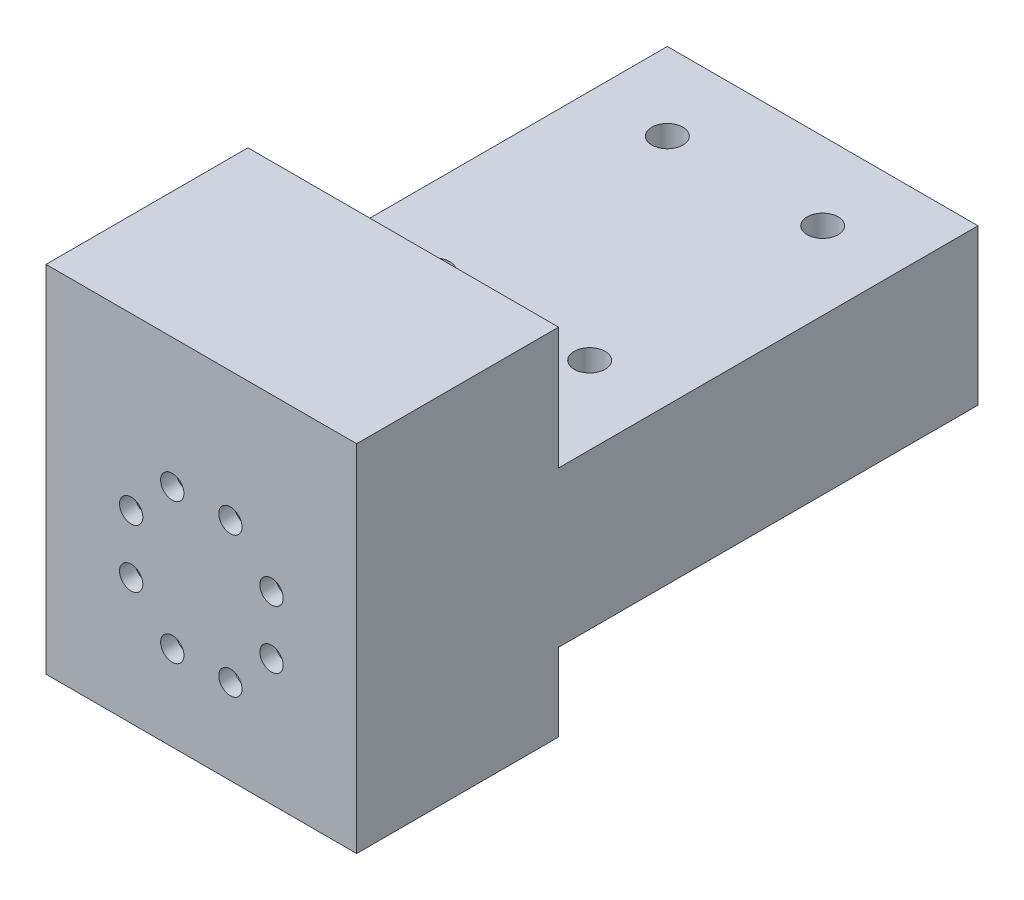
from build123d import *

# Parameters (mm, degrees)
CROQUIS1_W              = 40
CROQUIS1_H              = 40
SALIENTE_EXTRUIR1_DEPTH = 4
CROQUIS2_R              = 1.5
CORTAR_EXTRUIR1_DEPTH   = 4
SALIENTE_EXTRUIR2_DEPTH = 20
CROQUIS4_W              = 40
CROQUIS4_H              = 40
SALIENTE_EXTRUIR3_DEPTH = 4
CROQUIS6_W              = 40
CROQUIS6_H              = 40
CORTAR_EXTRUIR3_DEPTH   = 2
CROQUIS7_W              = 40
CROQUIS7_H              = 20
SALIENTE_EXTRUIR4_DEPTH = 80
CROQUIS8_R              = 2
CORTAR_EXTRUIR4_DEPTH   = 31
CROQUIS9_R              = 2
CORTAR_EXTRUIR5_DEPTH   = 31
CROQUIS11_W             = 40
CROQUIS11_H             = 20
CORTAR_EXTRUIR6_DEPTH   = 26
CROQUIS13_W             = 40
CROQUIS13_H             = 26
SALIENTE_EXTRUIR5_DEPTH = 5.7


with BuildPart() as part:
    # Croquis1 → Saliente-Extruir1 (new body)
    with BuildSketch(Plane.XY):
        Rectangle(CROQUIS1_W, CROQUIS1_H)
    extrude(amount=SALIENTE_EXTRUIR1_DEPTH)

    # Croquis2 → Cortar-Extruir1 (cut)
    with BuildSketch(Plane.XY.offset(4)):
        with Locations((-9.034617948, -3.742261285)):
            Circle(CROQUIS2_R)
        with Locations((-9.034617948, 3.742261285)):
            Circle(CROQUIS2_R)
        with Locations((-3.742261285, 9.034617948)):
            Circle(CROQUIS2_R)
        with Locations((3.742261285, 9.034617948)):
            Circle(CROQUIS2_R)
        with Locations((9.034617948, 3.742261285)):
            Circle(CROQUIS2_R)
        with Locations((9.034617948, -3.742261285)):
            Circle(CROQUIS2_R)
        with Locations((3.742261285, -9.034617948)):
            Circle(CROQUIS2_R)
        with Locations((-3.742261285, -9.034617948)):
            Circle(CROQUIS2_R)
    extrude(amount=-CORTAR_EXTRUIR1_DEPTH, mode=Mode.SUBTRACT)

    # Croquis3 → Saliente-Extruir2 (add)
    with BuildSketch(Plane(origin=(0, 0, 0), x_dir=(-1, 0, 0), z_dir=(0, 0, -1))):
        Polygon((-16, -20), (-16, -16), (-16, 16), (16, 16), (16, -16), (16, -20), (20, -20), (20, 20), (-20, 20), (-20, -20), align=None)
    extrude(amount=SALIENTE_EXTRUIR2_DEPTH)

    # Croquis4 → Saliente-Extruir3 (add)
    with BuildSketch(Plane(origin=(0, 0, -20), x_dir=(-1, 0, 0), z_dir=(0, 0, -1))):
        Rectangle(CROQUIS4_W, CROQUIS4_H)
    extrude(amount=SALIENTE_EXTRUIR3_DEPTH)

    # Croquis6 → Cortar-Extruir3 (cut)
    with BuildSketch(Plane.XY.offset(4)):
        Rectangle(CROQUIS6_W, CROQUIS6_H)
    extrude(amount=-CORTAR_EXTRUIR3_DEPTH, mode=Mode.SUBTRACT)

    # Croquis7 → Saliente-Extruir4 (add)
    with BuildSketch(Plane(origin=(0, 0, -24), x_dir=(-1, 0, 0), z_dir=(0, 0, -1))):
        Rectangle(CROQUIS7_W, CROQUIS7_H)
    extrude(amount=SALIENTE_EXTRUIR4_DEPTH)

    # Croquis8 → Cortar-Extruir4 (cut, through all)
    with BuildSketch(Plane(origin=(0, 10, 0), x_dir=(1, 0, 0), z_dir=(0, 1, 0))):
        with Locations((-10, 38)):
            Circle(CROQUIS8_R)
        with Locations((10, 38)):
            Circle(CROQUIS8_R)
    extrude(amount=-CORTAR_EXTRUIR4_DEPTH, mode=Mode.SUBTRACT)

    # Croquis9 → Cortar-Extruir5 (cut, through all)
    with BuildSketch(Plane(origin=(0, 10, 0), x_dir=(1, 0, 0), z_dir=(0, 1, 0))):
        with Locations((10, 68)):
            Circle(CROQUIS9_R)
        with Locations((-10, 68)):
            Circle(CROQUIS9_R)
    extrude(amount=-CORTAR_EXTRUIR5_DEPTH, mode=Mode.SUBTRACT)

    # Croquis11 → Cortar-Extruir6 (cut)
    with BuildSketch(Plane(origin=(0, 0, -104), x_dir=(-1, 0, 0), z_dir=(0, 0, -1))):
        Rectangle(CROQUIS11_W, CROQUIS11_H)
    extrude(amount=-CORTAR_EXTRUIR6_DEPTH, mode=Mode.SUBTRACT)

    # Croquis13 → Saliente-Extruir5 (add)
    with BuildSketch(Plane(origin=(0, 20, 0), x_dir=(1, 0, 0), z_dir=(0, 1, 0))):
        with Locations((0, 11)):
            Rectangle(CROQUIS13_W, CROQUIS13_H)
    extrude(amount=SALIENTE_EXTRUIR5_DEPTH)


solid = part.part
